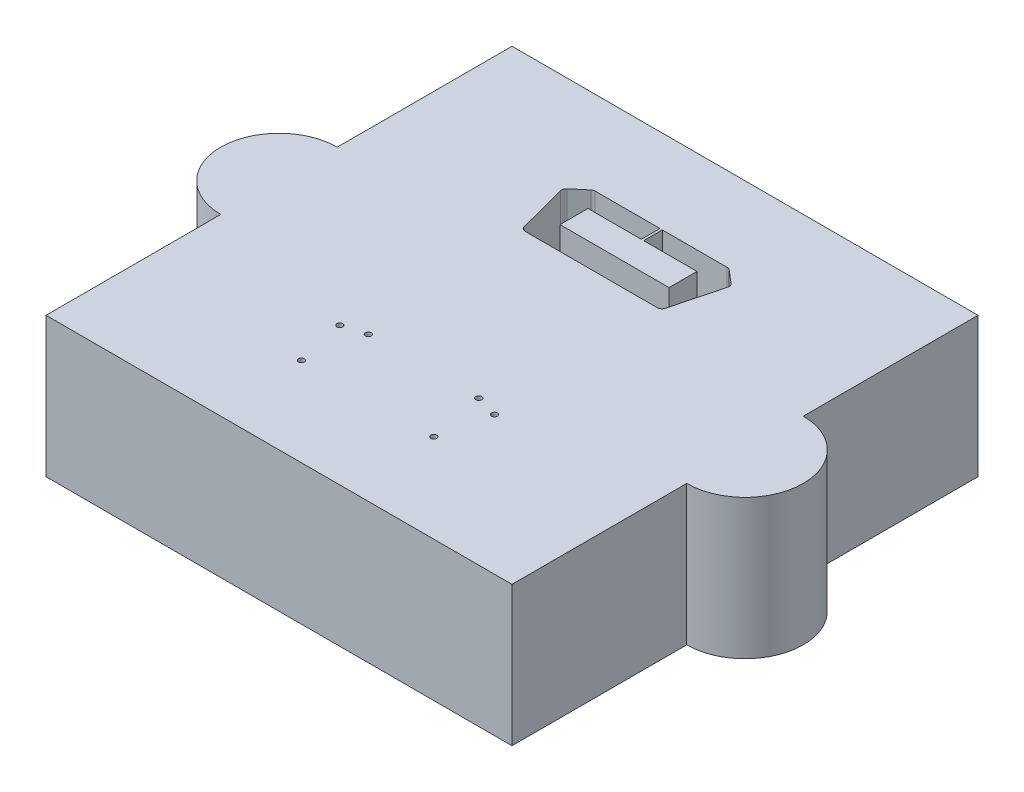
from build123d import *

# Parameters (mm, degrees)
BOSS_EXTRUDE1_DEPTH = 30
CUT_EXTRUDE2_DEPTH  = 20
SKETCH3_R           = 0.625
CUT_EXTRUDE3_DEPTH  = 10
SKETCH4_W           = 60
SKETCH4_H           = 30
CUT_EXTRUDE4_DEPTH  = 10
SKETCH5_W           = 60
SKETCH5_H           = 30
CUT_EXTRUDE5_DEPTH  = 20


with BuildPart() as part:
    # Sketch2 → Boss-Extrude1 (new body)
    with BuildSketch(Plane(origin=(0, 0, 0), x_dir=(1, 0, 0), z_dir=(0, 1, 0))):
        with BuildLine():
            Line((-50, -75), (50, -75))
            Line((50, -75), (50, -37.5))
            ThreePointArc((50, -37.5), (62.5, -25), (50, -12.5))
            Line((50, -12.5), (50, 25))
            Line((50, 25), (-50, 25))
            Line((-50, 25), (-50, -12.5))
            ThreePointArc((-50, -12.5), (-62.5, -25), (-50, -37.5))
            Line((-50, -37.5), (-50, -75))
        make_face()
    extrude(amount=-BOSS_EXTRUDE1_DEPTH)

    # Sketch1 → Cut-Extrude2 (cut)
    with BuildSketch(Plane(origin=(0, 0, 0), x_dir=(1, 0, 0), z_dir=(0, 1, 0))):
        with BuildLine():
            Line((-14.178620776, -8), (14.178620776, -8))
            ThreePointArc((14.178620776, -8), (14.789399734, -7.791801152), (15.145851741, -7.253898128))
            Line((15.145851741, -7.253898128), (17.939776994, 3.389626646))
            ThreePointArc((17.939776994, 3.389626646), (17.926022481, 3.944992277), (17.618005902, 4.407318956))
            Line((17.618005902, 4.407318956), (14.829510217, 6.763794182))
            ThreePointArc((14.829510217, 6.763794182), (14.527711383, 6.939093761), (14.184050345, 7))
            Line((14.184050345, 7), (0.25, 7))
            Line((0.25, 7), (0.25, 3))
            Line((0.25, 3), (11.7, 3))
            Line((11.7, 3), (11.7, -3))
            Line((11.7, -3), (-11.7, -3))
            Line((-11.7, -3), (-11.7, 3))
            Line((-11.7, 3), (-0.25, 3))
            Line((-0.25, 3), (-0.25, 7))
            Line((-0.25, 7), (-14.184050345, 7))
            ThreePointArc((-14.184050345, 7), (-14.527711383, 6.939093761), (-14.829510217, 6.763794182))
            Line((-14.829510217, 6.763794182), (-17.618005902, 4.407318956))
            ThreePointArc((-17.618005902, 4.407318956), (-17.926022481, 3.944992277), (-17.939776994, 3.389626646))
            Line((-17.939776994, 3.389626646), (-15.145851741, -7.253898128))
            ThreePointArc((-15.145851741, -7.253898128), (-14.789399734, -7.791801152), (-14.178620776, -8))
        make_face()
    extrude(amount=-CUT_EXTRUDE2_DEPTH, mode=Mode.SUBTRACT)

    # Sketch3 → Cut-Extrude3 (cut)
    with BuildSketch(Plane(origin=(0, 0, 0), x_dir=(1, 0, 0), z_dir=(0, 1, 0))):
        with Locations((-14.217473576, -55.961496156)):
            Circle(SKETCH3_R)
        with Locations((14.182526424, -55.961496156)):
            Circle(SKETCH3_R)
        with Locations((-16.617473576, -45.317971382)):
            Circle(SKETCH3_R)
        with Locations((16.582526424, -45.317971382)):
            Circle(SKETCH3_R)
        with Locations((-11.867473576, -43.961496156)):
            Circle(SKETCH3_R)
        with Locations((11.832526424, -43.961496156)):
            Circle(SKETCH3_R)
    extrude(amount=-CUT_EXTRUDE3_DEPTH, mode=Mode.SUBTRACT)

    # Sketch4 → Cut-Extrude4 (cut)
    with BuildSketch(Plane.XZ.offset(30)):
        Rectangle(SKETCH4_W, SKETCH4_H)
    extrude(amount=-CUT_EXTRUDE4_DEPTH, mode=Mode.SUBTRACT)

    # Sketch5 → Cut-Extrude5 (cut)
    with BuildSketch(Plane.XZ.offset(30)):
        with Locations((0, 50)):
            Rectangle(SKETCH5_W, SKETCH5_H)
    extrude(amount=-CUT_EXTRUDE5_DEPTH, mode=Mode.SUBTRACT)


solid = part.part
